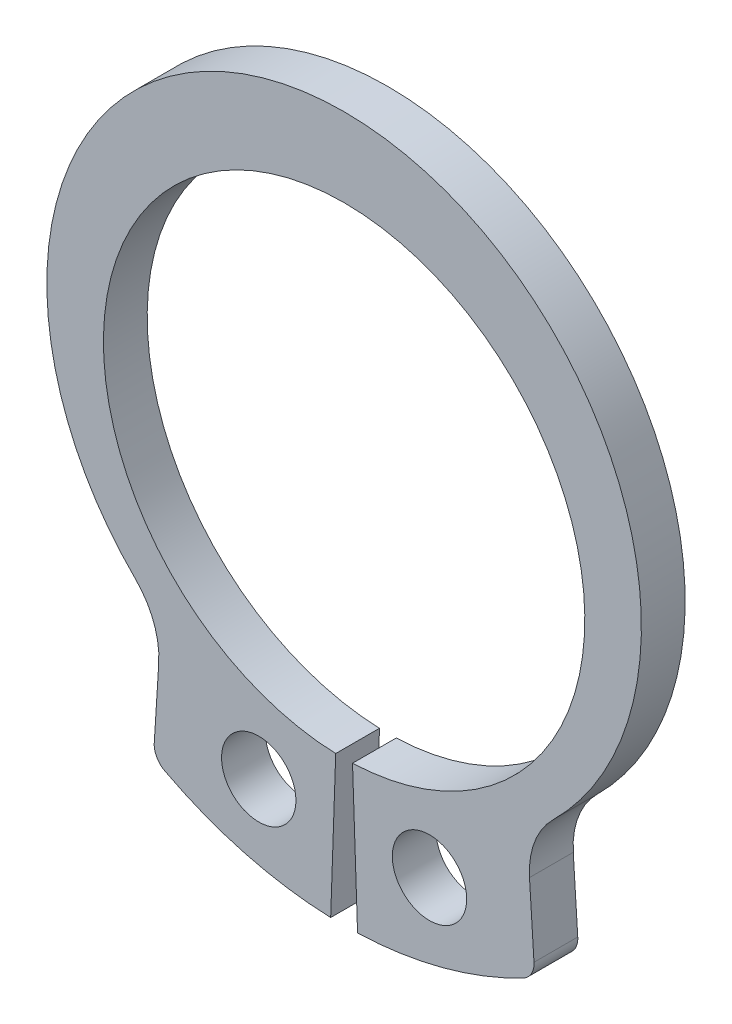
from build123d import *

# Parameters (mm, degrees)
SKETCH4_R           = 0.85
BOSS_EXTRUDE1_DEPTH = 0.5
FILLET1_R           = 1.826259158
FILLET2_R           = 0.456564789


with BuildPart() as part:
    # Sketch4 → Boss-Extrude1 (new body, symmetric)
    with BuildSketch(Plane.XY):
        with BuildLine():
            Line((-4.356605307, -7.652086329), (-4.179645962, -4.84670606))
            ThreePointArc((-4.179645962, -4.84670606), (-6.422848054, 2.717628201), (0, 7.3))
            Line((0, 7.3), (0, 5.5))
            ThreePointArc((0, 5.5), (-5.499162323, 0.095988235), (-0.191947232, -5.496649549))
            Line((-0.191947232, -5.496649549), (-0.307302772, -8.8))
            ThreePointArc((-0.307302772, -8.8), (-2.401548686, -8.471540527), (-4.356605307, -7.652086329))
        make_face()
        with Locations((-1.950801133, -6.88151398)):
            Circle(SKETCH4_R, mode=Mode.SUBTRACT)
    extrude(amount=BOSS_EXTRUDE1_DEPTH, both=True)

    # Fillet1
    fillet1_edges = [part.edges().sort_by_distance(p)[0] for p in [
        (-4.179645962, -4.84670606, 0),
    ]]
    fillet(fillet1_edges, radius=FILLET1_R)

    # Fillet2
    fillet2_edges = [part.edges().sort_by_distance(p)[0] for p in [
        (-4.356605307, -7.652086329, 0),
    ]]
    fillet(fillet2_edges, radius=FILLET2_R)

    # Mirror1: part across plane


with BuildPart() as part_1:
    add(part.part)
    add(part.part.mirror(Plane(origin=(0, 7.3, 0.5), x_dir=(0, 0, 1), z_dir=(-1, 0, 0))))


solid = part_1.part
